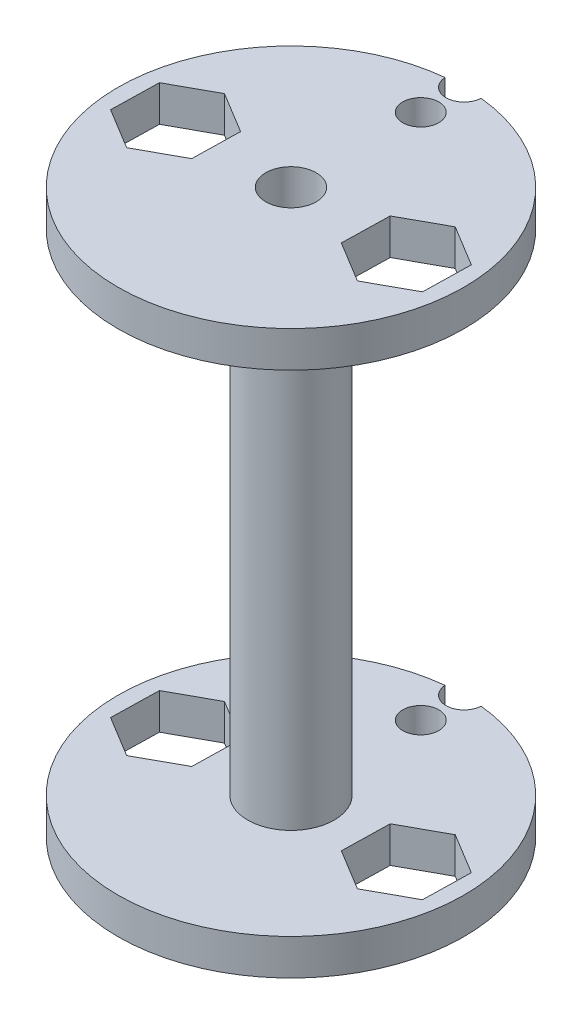
from build123d import *

# Parameters (mm, degrees)
SKETCH1_R           = 12
SKETCH1_R_2         = 1.75
BOSS_EXTRUDE1_DEPTH = 2.5
CUT_EXTRUDE3_DEPTH  = 2.5
SKETCH4_R           = 1.25
CUT_EXTRUDE4_DEPTH  = 5
SKETCH2_R           = 3
SKETCH2_R_2         = 1.75
BOSS_EXTRUDE2_DEPTH = 17


with BuildPart() as part:
    # Sketch1 → Boss-Extrude1 (new body)
    with BuildSketch(Plane(origin=(0, 0, 0), x_dir=(1, 0, 0), z_dir=(0, 1, 0))):
        Circle(SKETCH1_R)
        Circle(SKETCH1_R_2, mode=Mode.SUBTRACT)
    extrude(amount=BOSS_EXTRUDE1_DEPTH)

    # Sketch3 → Cut-Extrude3 (cut)
    with BuildSketch(Plane.XZ):
        Polygon((-5.161329605, 1.721273866), (-8.071331697, 3.318997608), (-10.910002092, 1.597723742), (-10.838670395, -1.721273866), (-7.928668303, -3.318997608), (-5.089997908, -1.597723742), align=None)
        Polygon((5.161329605, -1.721273866), (8.071331697, -3.318997608), (10.910002092, -1.597723742), (10.838670395, 1.721273866), (7.928668303, 3.318997608), (5.089997908, 1.597723742), align=None)
    extrude(amount=-CUT_EXTRUDE3_DEPTH, mode=Mode.SUBTRACT)

    # Sketch4 → Cut-Extrude4 (cut)
    with BuildSketch(Plane(origin=(0, 2.5, 0), x_dir=(1, 0, 0), z_dir=(0, 1, 0))):
        with Locations((0, 9)):
            Circle(SKETCH4_R)
        with Locations((0, 12)):
            Circle(SKETCH4_R)
    extrude(amount=-CUT_EXTRUDE4_DEPTH, mode=Mode.SUBTRACT)

    # Sketch2 → Boss-Extrude2 (add)
    with BuildSketch(Plane(origin=(0, 2.5, 0), x_dir=(1, 0, 0), z_dir=(0, 1, 0))):
        Circle(SKETCH2_R)
        Circle(SKETCH2_R_2, mode=Mode.SUBTRACT)
    extrude(amount=BOSS_EXTRUDE2_DEPTH)

    # Mirror7: part across plane


with BuildPart() as part_1:
    add(part.part)
    add(part.part.mirror(Plane.ZX.offset(19.5)))


solid = part_1.part
